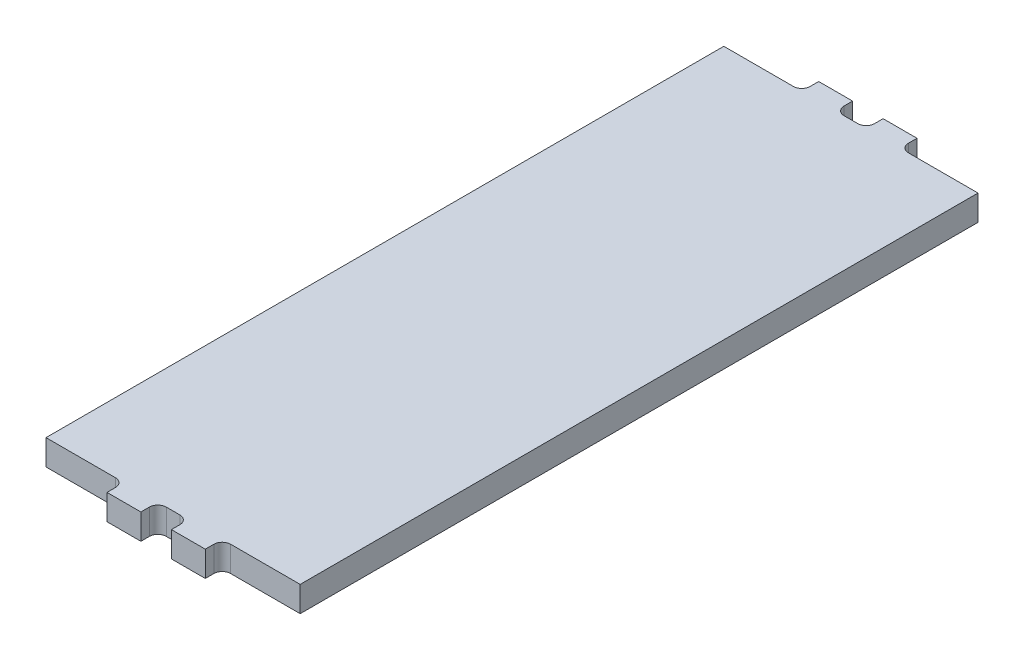
from build123d import *

# Parameters (mm, degrees)
BOSS_EXTRUDE1_DEPTH = 1.5
SKETCH2_W           = 2
SKETCH2_H           = 1.5
BOSS_EXTRUDE2_DEPTH = 0.01


with BuildPart() as part:
    # Sketch1 → Boss-Extrude1 (new body)
    with BuildSketch(Plane(origin=(0, 0, 0), x_dir=(1, 0, 0), z_dir=(0, 1, 0))):
        with BuildLine():
            Line((-7.5, -20.227321531), (-7.5, 19.772678469))
            Line((-7.5, 19.772678469), (-3.4, 19.772678469))
            ThreePointArc((-3.4, 19.772678469), (-3.046446609, 19.919125079), (-2.9, 20.272678469))
            Line((-2.9, 20.272678469), (-2.9, 20.772678469))
            Line((-2.9, 20.772678469), (-0.9, 20.772678469))
            Line((-0.9, 20.772678469), (-0.9, 20.272678469))
            ThreePointArc((-0.9, 20.272678469), (-0.753553391, 19.919125079), (-0.4, 19.772678469))
            Line((-0.4, 19.772678469), (0.4, 19.772678469))
            ThreePointArc((0.4, 19.772678469), (0.753553391, 19.919125079), (0.9, 20.272678469))
            Line((0.9, 20.272678469), (0.9, 20.772678469))
            Line((0.9, 20.772678469), (2.9, 20.772678469))
            Line((2.9, 20.772678469), (2.9, 20.272678469))
            ThreePointArc((2.9, 20.272678469), (3.046446609, 19.919125079), (3.4, 19.772678469))
            Line((3.4, 19.772678469), (7.5, 19.772678469))
            Line((7.5, 19.772678469), (7.5, -20.227321531))
            Line((7.5, -20.227321531), (3.4, -20.227321531))
            ThreePointArc((3.4, -20.227321531), (3.046446609, -20.37376814), (2.9, -20.727321531))
            Line((2.9, -20.727321531), (2.9, -21.227321531))
            Line((2.9, -21.227321531), (0.9, -21.227321531))
            Line((0.9, -21.227321531), (0.9, -20.727321531))
            ThreePointArc((0.9, -20.727321531), (0.753553391, -20.37376814), (0.4, -20.227321531))
            Line((0.4, -20.227321531), (-0.4, -20.227321531))
            ThreePointArc((-0.4, -20.227321531), (-0.753553391, -20.37376814), (-0.9, -20.727321531))
            Line((-0.9, -20.727321531), (-0.9, -21.227321531))
            Line((-0.9, -21.227321531), (-2.9, -21.227321531))
            Line((-2.9, -21.227321531), (-2.9, -20.727321531))
            ThreePointArc((-2.9, -20.727321531), (-3.046446609, -20.37376814), (-3.4, -20.227321531))
            Line((-3.4, -20.227321531), (-7.5, -20.227321531))
        make_face()
    extrude(amount=BOSS_EXTRUDE1_DEPTH)

    # Sketch2 → Boss-Extrude2 (add)
    with BuildSketch(Plane.XZ):
        with Locations((-1.95, -17.177321531)):
            Rectangle(SKETCH2_W, SKETCH2_H)
        with Locations((1.95, -17.177321531)):
            Rectangle(SKETCH2_W, SKETCH2_H)
        with Locations((-1.95, -14.177321531)):
            Rectangle(SKETCH2_W, SKETCH2_H)
        with Locations((1.95, -14.177321531)):
            Rectangle(SKETCH2_W, SKETCH2_H)
        with Locations((-1.95, -11.177321531)):
            Rectangle(SKETCH2_W, SKETCH2_H)
        with Locations((-1.95, -8.177321531)):
            Rectangle(SKETCH2_W, SKETCH2_H)
        with Locations((-1.95, -5.177321531)):
            Rectangle(SKETCH2_W, SKETCH2_H)
        with Locations((-1.95, -2.177321531)):
            Rectangle(SKETCH2_W, SKETCH2_H)
        with Locations((-1.95, 0.822678469)):
            Rectangle(SKETCH2_W, SKETCH2_H)
        with Locations((-1.95, 3.822678469)):
            Rectangle(SKETCH2_W, SKETCH2_H)
        with Locations((-1.95, 6.822678469)):
            Rectangle(SKETCH2_W, SKETCH2_H)
        with Locations((1.95, 6.822678469)):
            Rectangle(SKETCH2_W, SKETCH2_H)
        with Locations((-1.95, 9.822678469)):
            Rectangle(SKETCH2_W, SKETCH2_H)
        with Locations((1.95, 9.822678469)):
            Rectangle(SKETCH2_W, SKETCH2_H)
    extrude(amount=BOSS_EXTRUDE2_DEPTH)


solid = part.part
